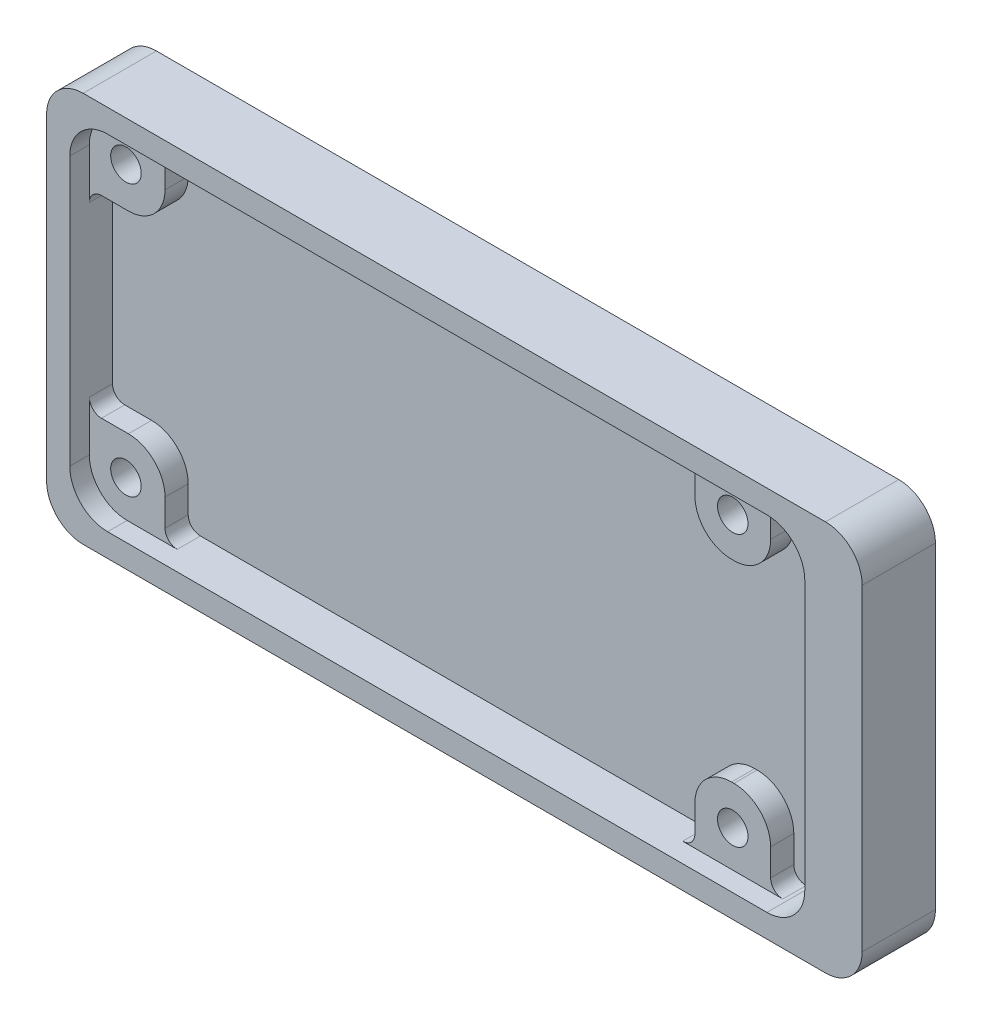
from build123d import *

# Parameters (mm, degrees)
EXTRUDE_1_DEPTH     = 6
CUT_EXTRUDE_1_DEPTH = 3.5
EXTRUDE_2_DEPTH     = 1.9
SKETCH_4_R          = 1.25
CUT_EXTRUDE_2_DEPTH = 7
SKETCH_11_R         = 2.4
CUT_EXTRUDE_3_DEPTH = 2.5
FILLET_1_R          = 1


with BuildPart() as part:
    # Эскиз1 → Бобышка-Вытянуть1 (new body)
    with BuildSketch(Plane.XY):
        with BuildLine():
            Line((3, 0), (63.8, 0))
            ThreePointArc((63.8, 0), (65.921320344, 0.878679656), (66.8, 3))
            Line((66.8, 3), (66.8, 29))
            ThreePointArc((66.8, 29), (65.921320344, 31.121320344), (63.8, 32))
            Line((63.8, 32), (3, 32))
            ThreePointArc((3, 32), (0.878679656, 31.121320344), (0, 29))
            Line((0, 29), (0, 3))
            ThreePointArc((0, 3), (0.878679656, 0.878679656), (3, 0))
        make_face()
    extrude(amount=EXTRUDE_1_DEPTH)

    # Эскиз2 → Вырез-Вытянуть1 (cut)
    with BuildSketch(Plane.XY.offset(6)):
        with BuildLine():
            Line((5, 30.1), (59, 30.1))
            ThreePointArc((59, 30.1), (61.192031022, 29.192031022), (62.1, 27))
            Line((62.1, 27), (62.1, 5))
            ThreePointArc((62.1, 5), (61.192031022, 2.807968978), (59, 1.9))
            Line((59, 1.9), (5, 1.9))
            ThreePointArc((5, 1.9), (2.807968978, 2.807968978), (1.9, 5))
            Line((1.9, 5), (1.9, 27))
            ThreePointArc((1.9, 27), (2.807968978, 29.192031022), (5, 30.1))
        make_face()
    extrude(amount=-CUT_EXTRUDE_1_DEPTH, mode=Mode.SUBTRACT)

    # Эскиз3 → Бобышка-Вытянуть2 (add)
    with BuildSketch(Plane.XY.offset(2.5)):
        with BuildLine():
            Line((4.9, 30.1), (8.1, 30.1))
            Line((8.1, 30.1), (8.1, 26.9))
            ThreePointArc((8.1, 26.9), (7.221320344, 24.778679656), (5.1, 23.9))
            Line((5.1, 23.9), (1.9, 23.9))
            Line((1.9, 23.9), (1.9, 27.1))
            ThreePointArc((1.9, 27.1), (2.778679656, 29.221320344), (4.9, 30.1))
        make_face()
        with BuildLine():
            Line((1.9, 8.1), (5.1, 8.1))
            ThreePointArc((5.1, 8.1), (7.221320344, 7.221320344), (8.1, 5.1))
            Line((8.1, 5.1), (8.1, 1.9))
            Line((8.1, 1.9), (4.9, 1.9))
            ThreePointArc((4.9, 1.9), (2.778679656, 2.778679656), (1.9, 4.9))
            Line((1.9, 4.9), (1.9, 8.1))
        make_face()
        with BuildLine():
            Line((51.5, 30.1), (57.7, 30.1))
            Line((57.7, 30.1), (57.7, 26.9))
            ThreePointArc((57.7, 26.9), (56.821320344, 24.778679656), (54.7, 23.9))
            Line((54.7, 23.9), (54.5, 23.9))
            ThreePointArc((54.5, 23.9), (52.378679656, 24.778679656), (51.5, 26.9))
            Line((51.5, 26.9), (51.5, 30.1))
        make_face()
        with BuildLine():
            Line((51.5, 1.9), (57.7, 1.9))
            Line((57.7, 1.9), (57.7, 5.1))
            ThreePointArc((57.7, 5.1), (56.821320344, 7.221320344), (54.7, 8.1))
            Line((54.7, 8.1), (54.5, 8.1))
            ThreePointArc((54.5, 8.1), (52.378679656, 7.221320344), (51.5, 5.1))
            Line((51.5, 5.1), (51.5, 1.9))
        make_face()
    extrude(amount=EXTRUDE_2_DEPTH)

    # Эскиз4 → Вырез-Вытянуть2 (cut, through all)
    with BuildSketch(Plane(origin=(0, 0, 0), x_dir=(-1, 0, 0), z_dir=(0, 0, -1))):
        with Locations((-54.6, 27.1)):
            Circle(SKETCH_4_R)
        with Locations((-4.9, 27.1)):
            Circle(SKETCH_4_R)
        with Locations((-4.9, 4.9)):
            Circle(SKETCH_4_R)
        with Locations((-54.6, 4.9)):
            Circle(SKETCH_4_R)
    extrude(amount=-CUT_EXTRUDE_2_DEPTH, mode=Mode.SUBTRACT)

    # Эскиз11 → Вырез-Вытянуть3 (cut)
    with BuildSketch(Plane(origin=(0, 0, 0), x_dir=(-1, 0, 0), z_dir=(0, 0, -1))):
        with Locations((-54.6, 27.1)):
            Circle(SKETCH_11_R)
        with Locations((-4.9, 27.1)):
            Circle(SKETCH_11_R)
        with Locations((-54.6, 4.9)):
            Circle(SKETCH_11_R)
        with Locations((-4.9, 4.9)):
            Circle(SKETCH_11_R)
    extrude(amount=-CUT_EXTRUDE_3_DEPTH, mode=Mode.SUBTRACT)

    # Скругление1
    fillet_1_edges = [part.edges().sort_by_distance(p)[0] for p in [
        (1.9, 8.1, 3.45),
        (8.1, 1.9, 3.45),
        (1.9, 23.9, 3.45),
        (8.1, 30.1, 3.45),
        (51.5, 30.1, 3.45),
        (57.7, 30.1, 3.45),
        (51.5, 1.9, 3.45),
        (57.7, 1.9, 3.45),
    ]]
    fillet(fillet_1_edges, radius=FILLET_1_R)


solid = part.part
